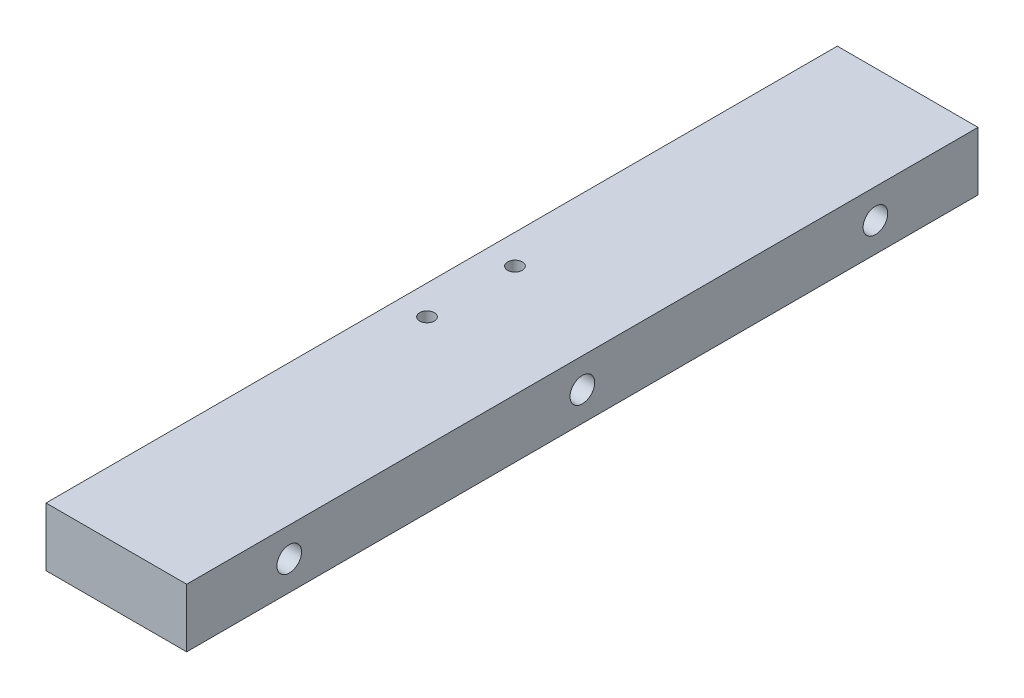
from build123d import *

# Parameters (mm, degrees)
SKETCH1_W                 = 24
SKETCH1_H                 = 135
BOSS_EXTRUDE1_DEPTH       = 10
M5X0_8_TAPPED_HOLE1_D     = 4.2
M5X0_8_TAPPED_HOLE1_DEPTH = 12.4
M5X0_8_TAPPED_HOLE1_TIP   = 1.2618073
M5X0_8_TAPPED_HOLE2_D     = 4.2
M5X0_8_TAPPED_HOLE2_DEPTH = 12.4
M5X0_8_TAPPED_HOLE2_TIP   = 1.2618073
M3X0_5_TAPPED_HOLE1_D     = 2.5


with BuildPart() as part:
    # Sketch1 → Boss-Extrude1 (new body)
    with BuildSketch(Plane(origin=(0, 0, 0), x_dir=(1, 0, 0), z_dir=(0, 1, 0))):
        with Locations((12, 0)):
            Rectangle(SKETCH1_W, SKETCH1_H)
    extrude(amount=BOSS_EXTRUDE1_DEPTH)

    # M5x0.8 Tapped Hole1
    with Locations(Plane(origin=(24, 0, 0), x_dir=(0, 0, -1), z_dir=(1, 0, 0))):
        with Locations((0, 5), (-50, 5), (50, 5)):
            Hole(M5X0_8_TAPPED_HOLE1_D / 2, depth=M5X0_8_TAPPED_HOLE1_DEPTH)
            with Locations((0, 0, -(M5X0_8_TAPPED_HOLE1_DEPTH + M5X0_8_TAPPED_HOLE1_TIP / 2))):  # 118° drill point
                Cone(0, M5X0_8_TAPPED_HOLE1_D / 2, M5X0_8_TAPPED_HOLE1_TIP, mode=Mode.SUBTRACT)

    # M5x0.8 Tapped Hole2
    with Locations(Plane.ZY):
        with Locations((50, 5), (0, 5), (-50, 5)):
            Hole(M5X0_8_TAPPED_HOLE2_D / 2, depth=M5X0_8_TAPPED_HOLE2_DEPTH)
            with Locations((0, 0, -(M5X0_8_TAPPED_HOLE2_DEPTH + M5X0_8_TAPPED_HOLE2_TIP / 2))):  # 118° drill point
                Cone(0, M5X0_8_TAPPED_HOLE2_D / 2, M5X0_8_TAPPED_HOLE2_TIP, mode=Mode.SUBTRACT)

    # M3x0.5 Tapped Hole1 (through all)
    with Locations(Plane(origin=(0, 10, 0), x_dir=(-1, 0, 0), z_dir=(0, 1, 0))):
        with Locations((-5, -7.5), (-5, 7.5)):
            Hole(M3X0_5_TAPPED_HOLE1_D / 2)


solid = part.part
